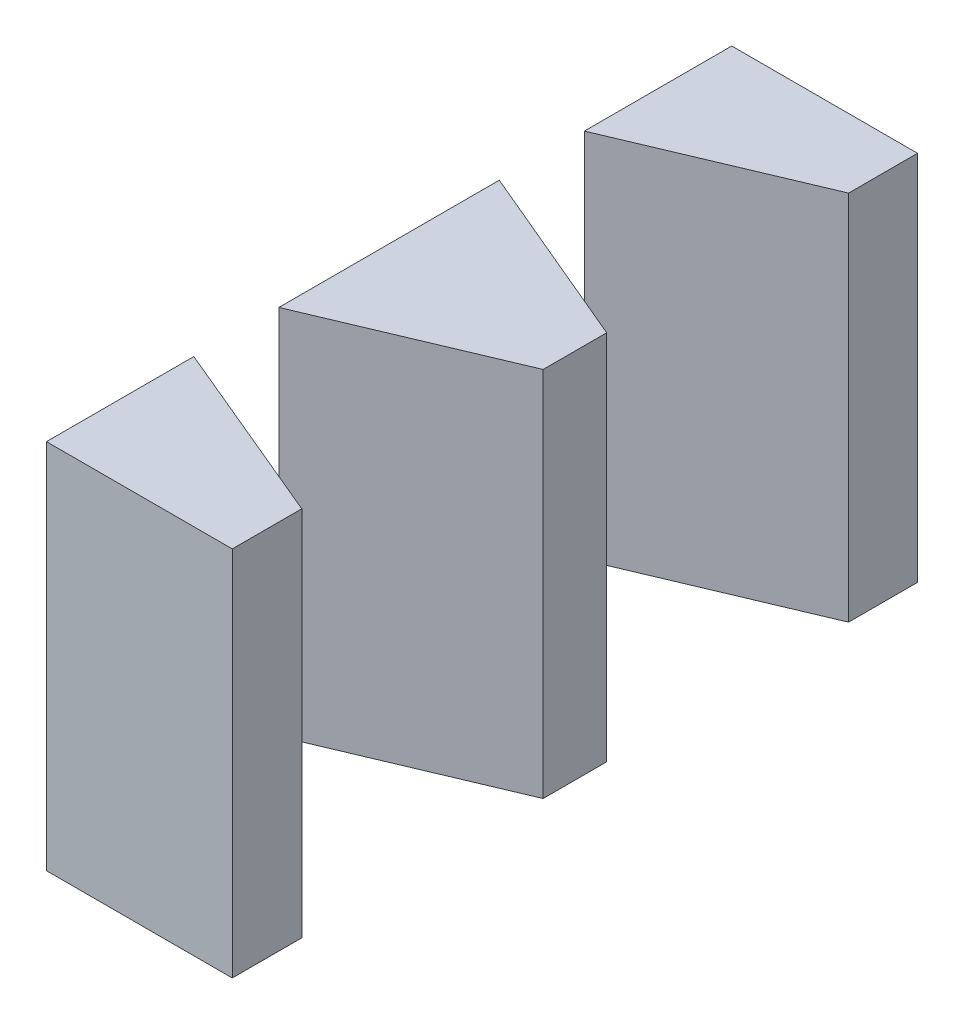
from build123d import *

# Parameters (mm, degrees)
SKETCH1_W               = 7.5
SKETCH1_H               = 27.66
BOSS_EXTRUDE1_DEPTH     = 25
SKETCH2_W               = 7.5
SKETCH2_H               = 27.66
CUT_EXTRUDE1_DEPTH      = 10
CUT_EXTRUDE2_DEPTH      = 1
CUT_EXTRUDE2_DEPTH_BACK = 16
CUT_EXTRUDE3_DEPTH      = 1
CUT_EXTRUDE3_DEPTH_BACK = 16


with BuildPart() as part:
    # Sketch1 → Boss-Extrude1 (new body)
    with BuildSketch(Plane(origin=(0, 0, 0), x_dir=(1, 0, 0), z_dir=(0, 1, 0))):
        with Locations((3.75, 13.83)):
            Rectangle(SKETCH1_W, SKETCH1_H)
    extrude(amount=BOSS_EXTRUDE1_DEPTH)

    # Sketch2 → Cut-Extrude1 (cut)
    with BuildSketch(Plane.XZ):
        with Locations((3.75, -13.83)):
            Rectangle(SKETCH2_W, SKETCH2_H)
    extrude(amount=-CUT_EXTRUDE1_DEPTH, mode=Mode.SUBTRACT)

    # Sketch3 → Cut-Extrude2 (cut, two sides)
    with BuildSketch(Plane.XZ.offset(-10)) as cut_extrude2_sk:
        Polygon((0, -5.948150323), (0, -6.381849677), (7.5, -3.239049355), (7.5, -2.805350002), align=None)
        Polygon((7.5, -12.112920844), (0, -8.947920844), (0, -9.382079156), (7.5, -12.547079156), align=None)
        Polygon((0, -18.277920844), (0, -18.712079156), (7.5, -15.547079156), (7.5, -15.112920844), align=None)
        Polygon((7.5, -24.442920844), (0, -21.277920844), (0, -21.712079156), (7.5, -24.877079156), align=None)
    extrude(amount=CUT_EXTRUDE2_DEPTH, mode=Mode.SUBTRACT)
    extrude(cut_extrude2_sk.sketch, amount=-CUT_EXTRUDE2_DEPTH_BACK, mode=Mode.SUBTRACT)

    # Sketch4 → Cut-Extrude3 (cut, two sides)
    with BuildSketch(Plane.XZ.offset(-10)) as cut_extrude3_sk:
        Polygon((0, -18.712079156), (7.5, -15.547079156), (7.5, -24.442920844), (0, -21.277920844), align=None)
        Polygon((0, -6.381849677), (7.5, -3.239049355), (7.5, -12.112920844), (0, -8.947920844), align=None)
    extrude(amount=CUT_EXTRUDE3_DEPTH, mode=Mode.SUBTRACT)
    extrude(cut_extrude3_sk.sketch, amount=-CUT_EXTRUDE3_DEPTH_BACK, mode=Mode.SUBTRACT)


solid = part.part
